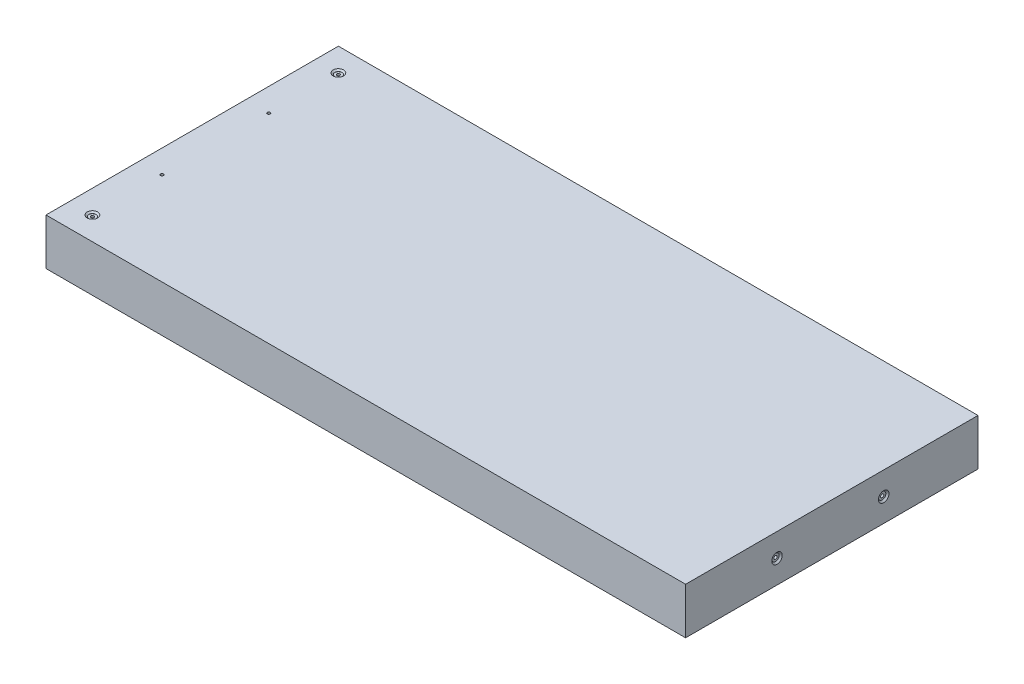
from build123d import *

# Parameters (mm, degrees)
SKETCH1_W                                   = 350
SKETCH1_H                                   = 160
BOSS_EXTRUDE1_DEPTH                         = 25.4
CBORE_FOR_0_BINDING_HEAD_MACHINE_SC_2_COUNT = 2
CBORE_FOR_0_BINDING_HEAD_MACHINE_SC_2_PITCH = 58.4
CBORE_FOR_0_BINDING_HEAD_MACHINE_SC_3_COUNT = 2
CBORE_FOR_0_BINDING_HEAD_MACHINE_SC_3_PITCH = 134.6
CBORE_FOR_0_BINDING_HEAD_MACHINE_SC_4_COUNT = 2
CBORE_FOR_0_BINDING_HEAD_MACHINE_SC_4_PITCH = 58.4


with BuildPart() as part:
    # Sketch1 → Boss-Extrude1 (new body)
    with BuildSketch(Plane(origin=(0, 0, 0), x_dir=(1, 0, 0), z_dir=(0, 1, 0))):
        Rectangle(SKETCH1_W, SKETCH1_H)
    extrude(amount=BOSS_EXTRUDE1_DEPTH)

    # Sketch3 → CBORE for #0 Binding Head Machine Screw3 (revolve, cut)
    with BuildSketch(Plane(origin=(175, 12.7, 30), x_dir=(0, 0, -1), z_dir=(0, 1, 0))):
        Polygon((0, 0), (0, 30.53416509), (0.889, 30), (0.889, 0.8128), (1.98501, 0.8128), (1.98501, 0.87249), (2.8575, 0), align=None)
    cbore_for_0_binding_head_machine_screw3 = revolve(axis=Axis((181.35, 12.7, 30), (-1, 0, 0)), mode=Mode.SUBTRACT)

    # CBORE for _0 Binding Head Machine Sc 2: CBORE for #0 Binding Head Machine Screw3 ×2
    with Locations(*[(0, 0, -i * CBORE_FOR_0_BINDING_HEAD_MACHINE_SC_2_PITCH) for i in range(1, CBORE_FOR_0_BINDING_HEAD_MACHINE_SC_2_COUNT)]):
        add(cbore_for_0_binding_head_machine_screw3, mode=Mode.SUBTRACT)

    # Sketch7 → CBORE for #0 Binding Head Machine Screw1 (revolve, cut)
    with BuildSketch(Plane(origin=(-162.3, 25.4, 67.3), x_dir=(0, 0, 1), z_dir=(1, 0, 0))):
        Polygon((0, 0), (0, 25.4), (0.80645, 25.4), (0.80645, 0.8128), (1.98501, 0.8128), (1.98501, 0.732106037), (2.8575, 0), align=None)
    cbore_for_0_binding_head_machine_screw1 = revolve(axis=Axis((-162.3, 31.75, 67.3), (0, -1, 0)), mode=Mode.SUBTRACT)

    # CBORE for _0 Binding Head Machine Sc 3: CBORE for #0 Binding Head Machine Screw1 ×2
    with Locations(*[(0, 0, -i * CBORE_FOR_0_BINDING_HEAD_MACHINE_SC_3_PITCH) for i in range(1, CBORE_FOR_0_BINDING_HEAD_MACHINE_SC_3_COUNT)]):
        add(cbore_for_0_binding_head_machine_screw1, mode=Mode.SUBTRACT)

    # Sketch9 → CBORE for #0 Binding Head Machine Screw2 (revolve, cut)
    with BuildSketch(Plane(origin=(-162.3, 0, -29.2), x_dir=(0, 0, -1), z_dir=(1, 0, 0))):
        Polygon((0, 0), (0, 25.4), (0.80645, 25.4), (0.80645, 0.8128), (1.98501, 0.8128), (1.98501, 0.732106037), (2.8575, 0), align=None)
    cbore_for_0_binding_head_machine_screw2 = revolve(axis=Axis((-162.3, -6.35, -29.2), (0, 1, 0)), mode=Mode.SUBTRACT)

    # CBORE for _0 Binding Head Machine Sc 4: CBORE for #0 Binding Head Machine Screw2 ×2
    with Locations(*[(0, 0, i * CBORE_FOR_0_BINDING_HEAD_MACHINE_SC_4_PITCH) for i in range(1, CBORE_FOR_0_BINDING_HEAD_MACHINE_SC_4_COUNT)]):
        add(cbore_for_0_binding_head_machine_screw2, mode=Mode.SUBTRACT)


solid = part.part
